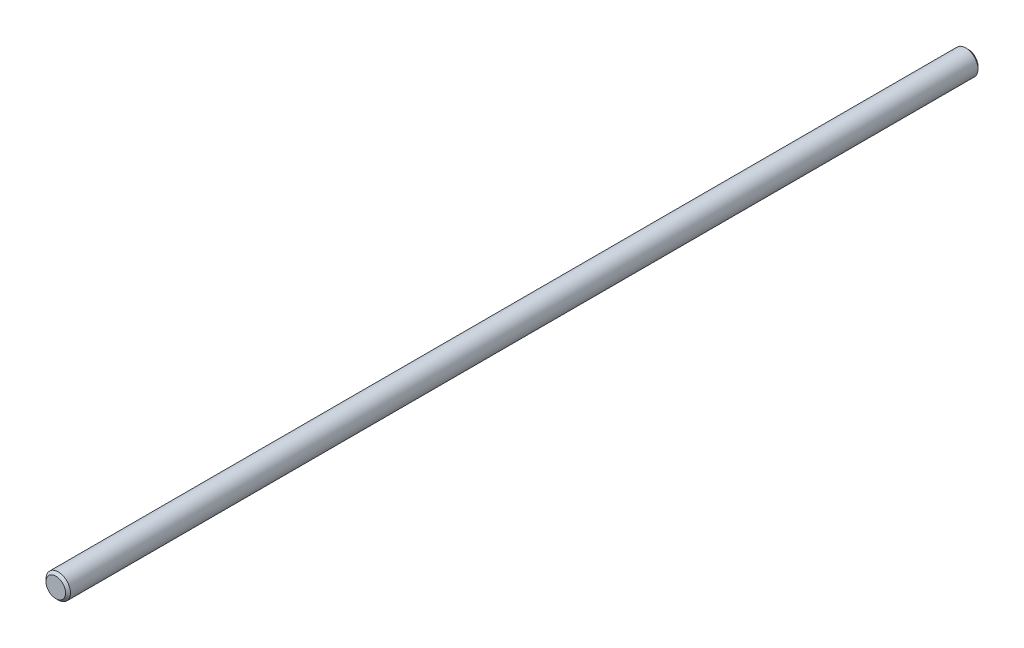
from build123d import *

# Parameters (mm, degrees)
SKETCH3_R           = 4.7625
BOSS_EXTRUDE1_DEPTH = 177.8
CHAMFER1_SIZE       = 0.9525


with BuildPart() as part:
    # Sketch3 → Boss-Extrude1 (new body, symmetric)
    with BuildSketch(Plane.XY):
        Circle(SKETCH3_R)
    extrude(amount=BOSS_EXTRUDE1_DEPTH, both=True)

    # Chamfer1
    chamfer1_edges = [part.edges().sort_by_distance(p)[0] for p in [
        (-4.7625, 0, -177.8),
        (-4.7625, 0, 177.8),
    ]]
    chamfer(chamfer1_edges, length=CHAMFER1_SIZE)


solid = part.part
